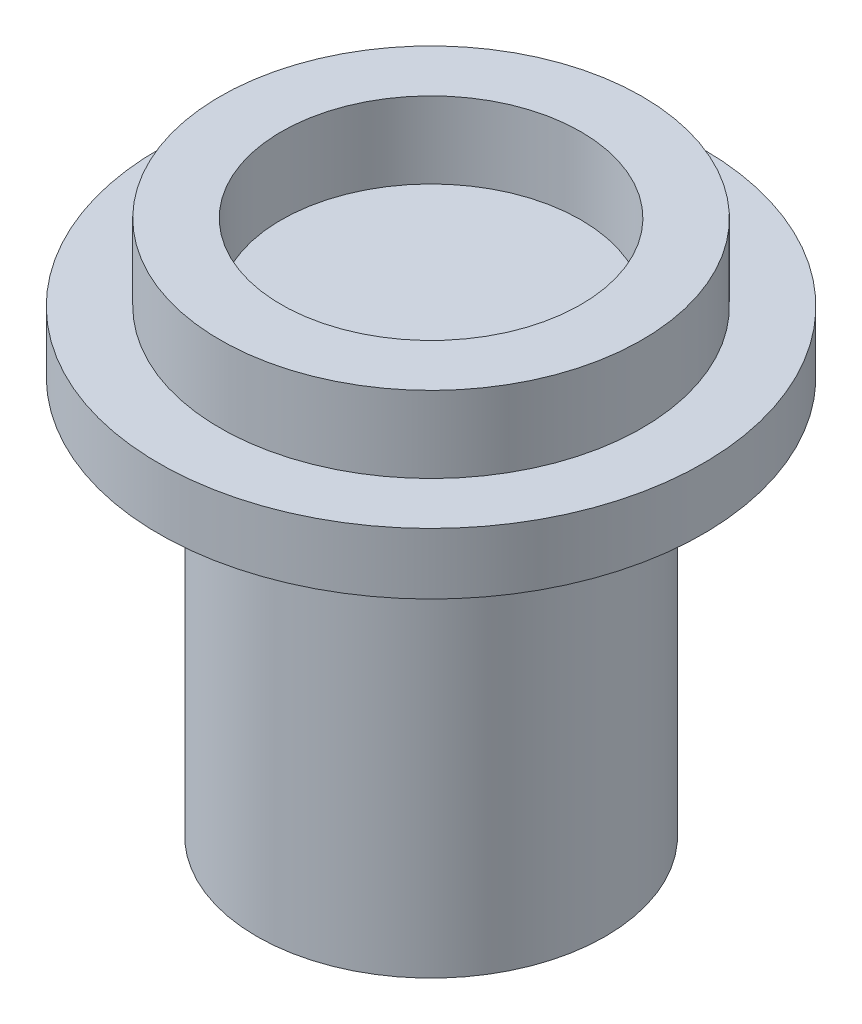
from build123d import *


with BuildPart() as part:
    # Sketch2 → Revolve3 (revolve)
    with BuildSketch(Plane.XY):
        Polygon((1.55, 1.180296702), (1.55, 7.680296702), (0, 7.680296702), (0, 8.680296702), (2.45, 8.680296702), (2.45, 9.928259415), (3.45, 9.928259415), (3.45, 8.680296702), (4.45, 8.680296702), (4.45, 7.680296702), (2.85, 7.680296702), (2.85, 1.180296702), align=None)
    revolve(axis=Axis((0, -1.788372775, 0), (0, 1, 0)))


solid = part.part
